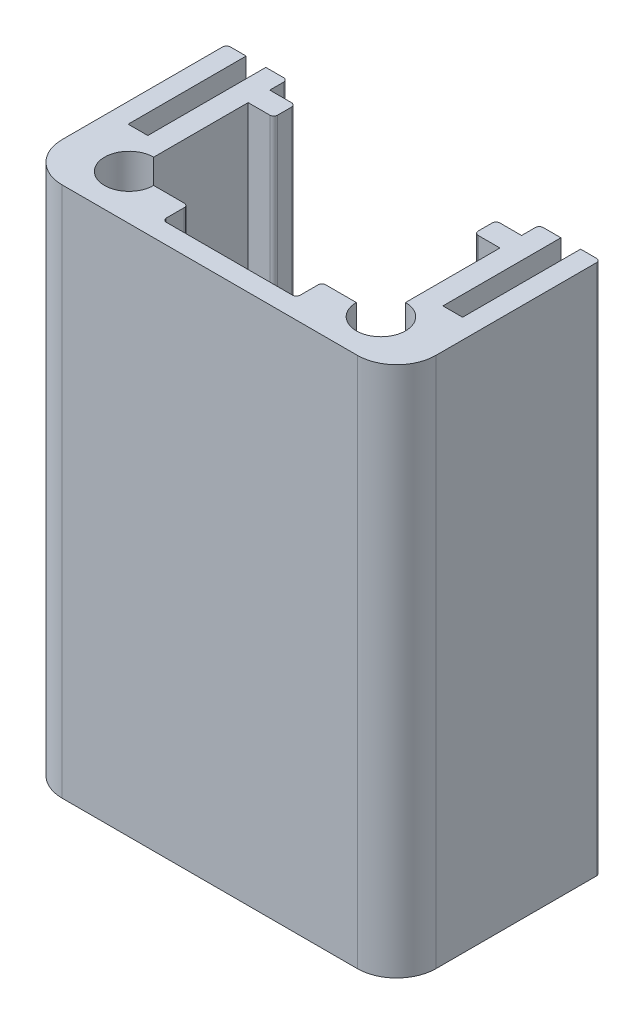
from build123d import *

# Parameters (mm, degrees)
EXTRUDE_1_DEPTH        = 27
CUT_EXTRUDE_1_REACH    = 29
SKETCH_3_W             = 1
SKETCH_3_H             = 7
SKETCH_8_W             = 12.8
SKETCH_8_H             = 27
CUT_EXTRUDE_4_DEPTH    = 1.9
CUT_EXTRUDE_5_REACH    = 29
SKETCH_9_R             = 1.15
SKETCH_9_W             = 6.8
SKETCH_9_H             = 1.3
CUT_EXTRUDE_START      = -27
SKETCH_11_W            = 3.1
SKETCH_11_H            = 1
CUT_EXTRUDE_6_DEPTH    = 27
FILLET_1_R             = 2
FILLET_2_R             = 0.2
HOLE_WIZARD_M3_1_D     = 2.5
HOLE_WIZARD_M3_1_DEPTH = 8.5
HOLE_WIZARD_M3_1_TIP   = 0.751075774


with BuildPart() as part:
    # 草图1 → 凸台-拉伸1 (new body)
    with BuildSketch(Plane(origin=(0, 0, 0), x_dir=(1, 0, 0), z_dir=(0, 1, 0))):
        Polygon((-9.5, 11.35), (-9.5, 0), (9.5, 0), (9.5, 11.35), (5.1, 11.35), (5.1, 8.35), (6.4, 8.35), (6.4, 2.3), (-6.4, 2.3), (-6.4, 8.35), (-5.1, 8.35), (-5.1, 11.35), align=None)
    extrude(amount=EXTRUDE_1_DEPTH)

    # 草图3 → 切除-拉伸1 (cut, up to next)
    with BuildSketch(Plane(origin=(0, 27, 0), x_dir=(1, 0, 0), z_dir=(0, 1, 0)), mode=Mode.PRIVATE) as cut_extrude_1_sk1:
        with Locations((-8, 7.85)):
            Rectangle(SKETCH_3_W, SKETCH_3_H)
    cut_extrude_1_tool1 = extrude(cut_extrude_1_sk1.sketch, amount=-CUT_EXTRUDE_1_REACH, mode=Mode.PRIVATE) & part.part
    add(cut_extrude_1_tool1.solids().sort_by_distance((-8, 27, -7.85))[0], mode=Mode.SUBTRACT)
    # 草图3 → 切除-拉伸1 (cut, up to next)
    with BuildSketch(Plane(origin=(0, 27, 0), x_dir=(1, 0, 0), z_dir=(0, 1, 0)), mode=Mode.PRIVATE) as cut_extrude_1_sk2:
        with Locations((8, 7.85)):
            Rectangle(SKETCH_3_W, SKETCH_3_H)
    cut_extrude_1_tool2 = extrude(cut_extrude_1_sk2.sketch, amount=-CUT_EXTRUDE_1_REACH, mode=Mode.PRIVATE) & part.part
    add(cut_extrude_1_tool2.solids().sort_by_distance((8, 27, -7.85))[0], mode=Mode.SUBTRACT)

    # 草图8 → 切除-拉伸4 (cut)
    with BuildSketch(Plane(origin=(0, 0, -11.35), x_dir=(-1, 0, 0), z_dir=(0, 0, -1))):
        with Locations((0, 13.5)):
            Rectangle(SKETCH_8_W, SKETCH_8_H)
    extrude(amount=-CUT_EXTRUDE_4_DEPTH, mode=Mode.SUBTRACT)

    # 草图9 → 切除-拉伸5 (cut, up to next)
    with BuildSketch(Plane.XZ, mode=Mode.PRIVATE) as cut_extrude_5_sk1:
        with Locations((-6.4, -2.3)):
            Circle(SKETCH_9_R)
    cut_extrude_5_tool1 = extrude(cut_extrude_5_sk1.sketch, amount=-CUT_EXTRUDE_5_REACH, mode=Mode.PRIVATE) & part.part
    add(cut_extrude_5_tool1.solids().sort_by_distance((-6.4, 0, -2.3))[0], mode=Mode.SUBTRACT)
    # 草图9 → 切除-拉伸5 (cut, up to next)
    with BuildSketch(Plane.XZ, mode=Mode.PRIVATE) as cut_extrude_5_sk2:
        with Locations((6.4, -2.3)):
            Circle(SKETCH_9_R)
    cut_extrude_5_tool2 = extrude(cut_extrude_5_sk2.sketch, amount=-CUT_EXTRUDE_5_REACH, mode=Mode.PRIVATE) & part.part
    add(cut_extrude_5_tool2.solids().sort_by_distance((6.4, 0, -2.3))[0], mode=Mode.SUBTRACT)
    # 草图9 → 切除-拉伸5 (cut, up to next)
    with BuildSketch(Plane.XZ, mode=Mode.PRIVATE) as cut_extrude_5_sk3:
        with Locations((0, -1.65)):
            Rectangle(SKETCH_9_W, SKETCH_9_H)
    cut_extrude_5_tool3 = extrude(cut_extrude_5_sk3.sketch, amount=-CUT_EXTRUDE_5_REACH, mode=Mode.PRIVATE) & part.part
    add(cut_extrude_5_tool3.solids().sort_by_distance((0, 0, -1.65))[0], mode=Mode.SUBTRACT)

    # 草图11 → 切除-拉伸6 (cut)
    with BuildSketch(Plane(origin=(0, 27, 0), x_dir=(1, 0, 0), z_dir=(0, 1, 0)).offset(CUT_EXTRUDE_START)):
        with Locations((7.95, 10.85)):
            Rectangle(SKETCH_11_W, SKETCH_11_H)
        with Locations((-7.95, 10.85)):
            Rectangle(SKETCH_11_W, SKETCH_11_H)
    extrude(amount=CUT_EXTRUDE_6_DEPTH, mode=Mode.SUBTRACT)

    # 圆角1
    fillet_1_edges = [part.edges().sort_by_distance(p)[0] for p in [
        (9.5, 13.5, 0),
        (-9.5, 13.5, 0),
    ]]
    fillet(fillet_1_edges, radius=FILLET_1_R)

    # 圆角2
    fillet_2_edges = [part.edges().sort_by_distance(p)[0] for p in [
        (-3.4, 13.5, -2.3),
        (-3.4, 13.5, -1),
        (3.4, 13.5, -1),
        (3.4, 13.5, -2.3),
        (9.5, 13.5, -10.35),
        (-9.5, 13.5, -10.35),
        (6.4, 13.5, -10.35),
        (-6.4, 13.5, -10.35),
        (-5.1, 13.5, -8.35),
        (5.1, 13.5, -8.35),
        (5.1, 13.5, -9.45),
        (-5.1, 13.5, -9.45),
    ]]
    fillet(fillet_2_edges, radius=FILLET_2_R)

    # M3 螺纹孔1
    with Locations(Plane(origin=(0, 27, 0), x_dir=(1, 0, 0), z_dir=(0, 1, 0))):
        with Locations((-6.4, 2.3), (6.4, 2.3)):
            Hole(HOLE_WIZARD_M3_1_D / 2, depth=HOLE_WIZARD_M3_1_DEPTH)
            with Locations((0, 0, -(HOLE_WIZARD_M3_1_DEPTH + HOLE_WIZARD_M3_1_TIP / 2))):  # 118° drill point
                Cone(0, HOLE_WIZARD_M3_1_D / 2, HOLE_WIZARD_M3_1_TIP, mode=Mode.SUBTRACT)


solid = part.part
